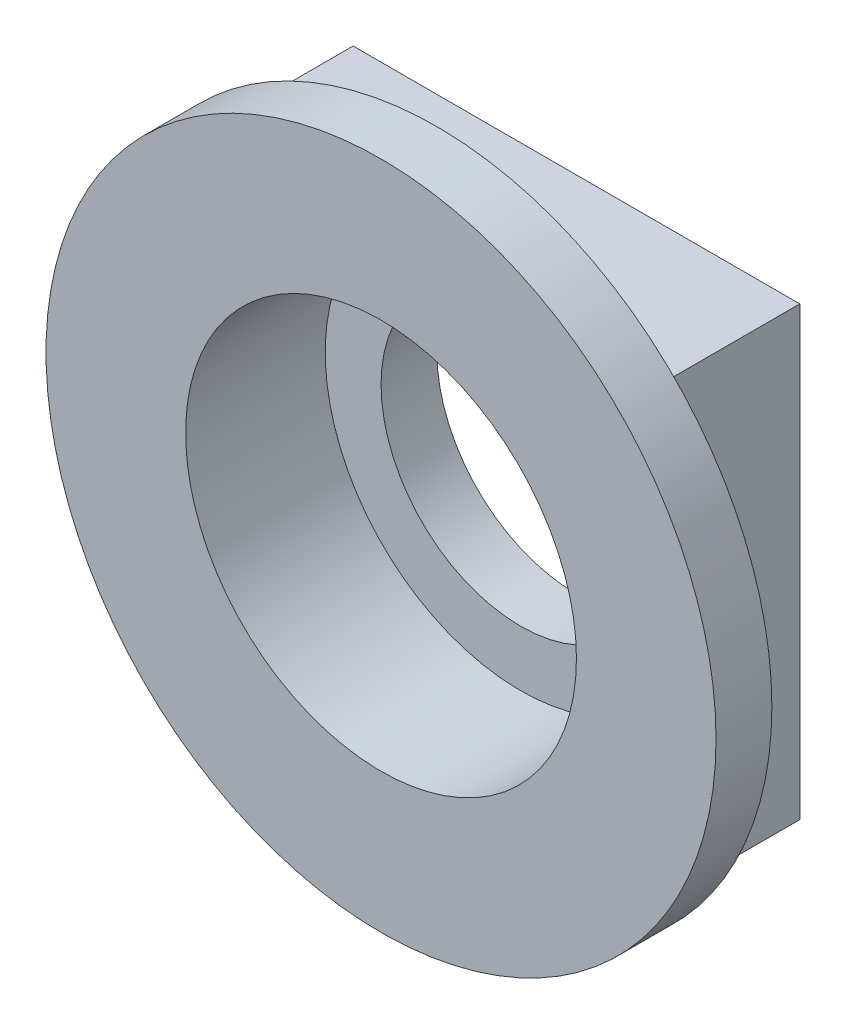
from build123d import *

# Parameters (mm, degrees)
SKIZZE1_R                       = 6
AUFSATZ_LINEAR_AUSTRAGEN1_DEPTH = 3.5
SKIZZE1_3_R                     = 3.5
SCHNITT_LINEAR_AUSTRAGEN1_DEPTH = 2.5
SKIZZE1_4_R                     = 2.5
SCHNITT_LINEAR_AUSTRAGEN3_DEPTH = 10.178779875
SCHNITT_LINEAR_START            = -1
SKIZZE1_5_OUTSIDE_W             = 17.466
SKIZZE1_5_OUTSIDE_H             = 17.466
SKIZZE1_5_OUTSIDE_W_2           = 8
SKIZZE1_5_OUTSIDE_H_2           = 8
SCHNITT_LINEAR_AUSTRAGEN4_DEPTH = 9.178779875


with BuildPart() as part:
    # Skizze1 → Aufsatz-Linear austragen1 (new body)
    with BuildSketch(Plane.XY):
        Circle(SKIZZE1_R)
    extrude(amount=-AUFSATZ_LINEAR_AUSTRAGEN1_DEPTH)

    # Skizze1_3 → Schnitt-Linear austragen1 (cut)
    with BuildSketch(Plane.XY):
        Circle(SKIZZE1_3_R)
    extrude(amount=-SCHNITT_LINEAR_AUSTRAGEN1_DEPTH, mode=Mode.SUBTRACT)

    # Skizze1_4 → Schnitt-Linear austragen3 (cut, through all)
    with BuildSketch(Plane.XY):
        Circle(SKIZZE1_4_R)
    extrude(amount=-SCHNITT_LINEAR_AUSTRAGEN3_DEPTH, mode=Mode.SUBTRACT)

    # Skizze1_5 outside → Schnitt-Linear austragen4 (cut, through all)
    with BuildSketch(Plane.XY.offset(SCHNITT_LINEAR_START)):
        Rectangle(SKIZZE1_5_OUTSIDE_W, SKIZZE1_5_OUTSIDE_H)
        Rectangle(SKIZZE1_5_OUTSIDE_W_2, SKIZZE1_5_OUTSIDE_H_2, mode=Mode.SUBTRACT)
    extrude(amount=-SCHNITT_LINEAR_AUSTRAGEN4_DEPTH, mode=Mode.SUBTRACT)


solid = part.part
